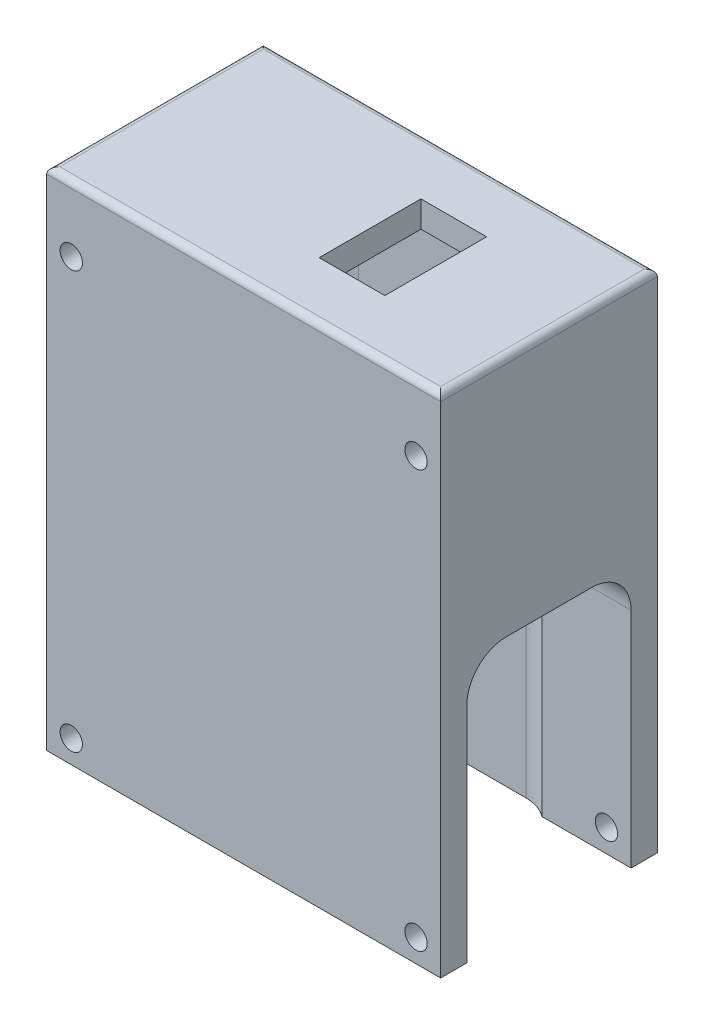
from build123d import *

# Parameters (mm, degrees)
SKETCH_1_W          = 60
SKETCH_1_H          = 33
EXTRUDE_1_DEPTH     = 77
CUT_EXTRUDE_1_DEPTH = 73
SKETCH_3_R          = 1.7
CUT_EXTRUDE_2_DEPTH = 34
CUT_EXTRUDE_3_DEPTH = 61
SKETCH_5_W          = 10
SKETCH_5_H          = 15.5
CUT_EXTRUDE_4_DEPTH = 5
FILLET_1_R          = 1


with BuildPart() as part:
    # ｽｹｯﾁ1 → ﾎﾞｽ - 押し出し1 (new body)
    with BuildSketch(Plane(origin=(0, 0, 0), x_dir=(1, 0, 0), z_dir=(0, 1, 0))):
        Rectangle(SKETCH_1_W, SKETCH_1_H)
    extrude(amount=EXTRUDE_1_DEPTH)

    # ｽｹｯﾁ2 → ｶｯﾄ - 押し出し1 (cut)
    with BuildSketch(Plane.XZ):
        with BuildLine():
            Line((12.75, 13.75), (-12.75, 13.75))
            ThreePointArc((-12.75, 13.75), (-16.992640687, 11.992640687), (-18.75, 7.75))
            Line((-18.75, 7.75), (-18.75, -7.75))
            ThreePointArc((-18.75, -7.75), (-16.992640687, -11.992640687), (-12.75, -13.75))
            Line((-12.75, -13.75), (12.75, -13.75))
            ThreePointArc((12.75, -13.75), (16.992640687, -11.992640687), (18.75, -7.75))
            Line((18.75, -7.75), (18.75, 7.75))
            ThreePointArc((18.75, 7.75), (16.992640687, 11.992640687), (12.75, 13.75))
        make_face()
    extrude(amount=-CUT_EXTRUDE_1_DEPTH, mode=Mode.SUBTRACT)

    # ｽｹｯﾁ3 → ｶｯﾄ - 押し出し2 (cut, through all)
    with BuildSketch(Plane.XY.offset(16.5)):
        with Locations((26.25, 3.5)):
            Circle(SKETCH_3_R)
        with Locations((26.25, 67)):
            Circle(SKETCH_3_R)
        with Locations((-26.25, 67)):
            Circle(SKETCH_3_R)
        with Locations((-26.25, 3.5)):
            Circle(SKETCH_3_R)
    extrude(amount=-CUT_EXTRUDE_2_DEPTH, mode=Mode.SUBTRACT)

    # ｽｹｯﾁ4 → ｶｯﾄ - 押し出し3 (cut, through all)
    with BuildSketch(Plane.ZY.offset(30)):
        with BuildLine():
            Line((6.5, 40), (-6.5, 40))
            ThreePointArc((-6.5, 40), (-10.742640687, 38.242640687), (-12.5, 34))
            Line((-12.5, 34), (-12.5, 0))
            Line((-12.5, 0), (12.5, 0))
            Line((12.5, 0), (12.5, 34))
            ThreePointArc((12.5, 34), (10.742640687, 38.242640687), (6.5, 40))
        make_face()
    extrude(amount=-CUT_EXTRUDE_3_DEPTH, mode=Mode.SUBTRACT)

    # ｽｹｯﾁ5 → ｶｯﾄ - 押し出し4 (cut, through all)
    with BuildSketch(Plane.XZ.offset(-73)):
        with Locations((7.75, 0)):
            Rectangle(SKETCH_5_W, SKETCH_5_H)
    extrude(amount=-CUT_EXTRUDE_4_DEPTH, mode=Mode.SUBTRACT)

    # ﾌｨﾚｯﾄ1
    fillet_1_edges = [part.edges().sort_by_distance(p)[0] for p in [
        (30, 77, 0),
        (0, 77, -16.5),
        (-30, 77, 0),
        (0, 77, 16.5),
    ]]
    fillet(fillet_1_edges, radius=FILLET_1_R)


solid = part.part
